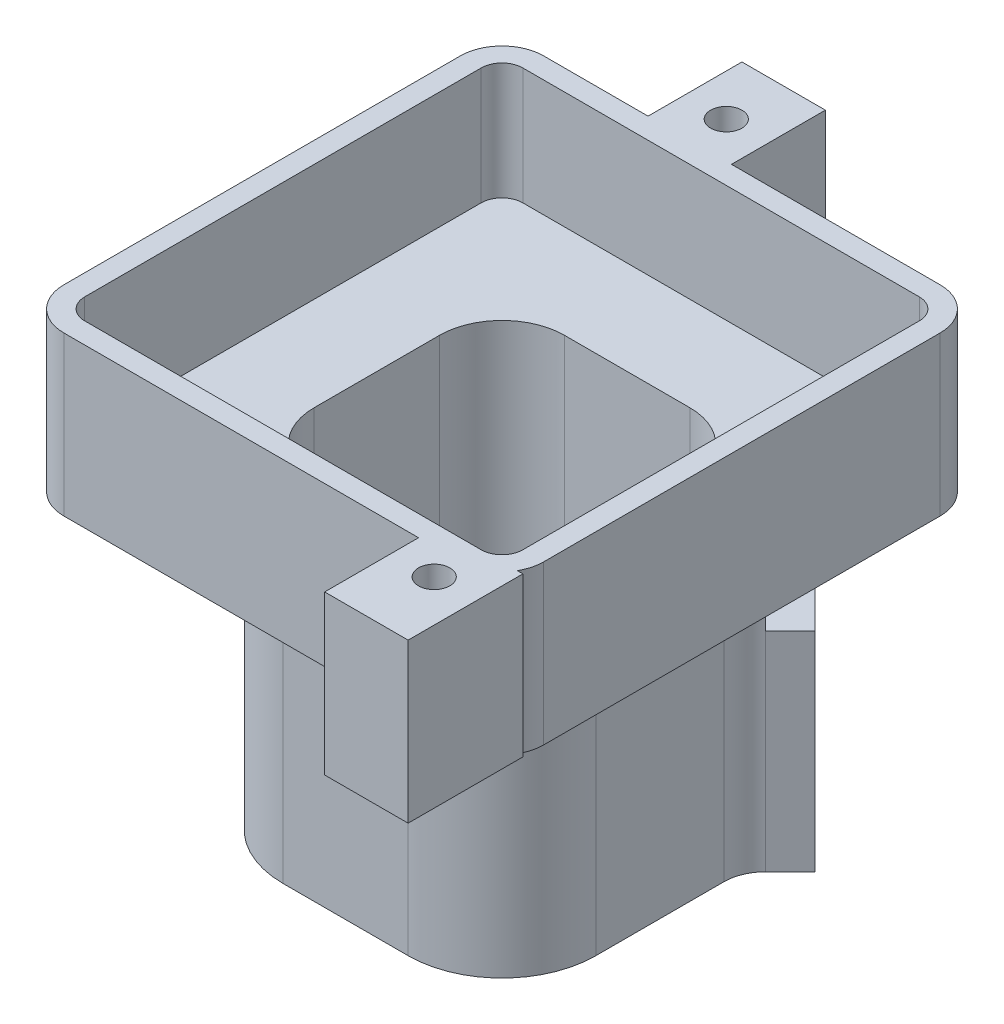
from build123d import *

# Parameters (mm, degrees)
SKETCH1_W                     = 7.5
SKETCH1_H                     = 7.5
BOSS_EXTRUDE1_DEPTH           = 7
SKETCH2_W                     = 11.5
SKETCH2_H                     = 11.5
BOSS_EXTRUDE2_DEPTH           = 3.8
SKETCH3_W                     = 6
SKETCH3_H                     = 6
CUT_EXTRUDE1_DEPTH            = 11.8
SKETCH6_W                     = 10.5
SKETCH6_H                     = 10.5
CUT_EXTRUDE3_DEPTH            = 2.8
FILLET1_R                     = 0.5
BOSS_EXTRUDE3_REACH           = 12.8
FILLET4_R                     = 1.5
FILLET2_R                     = 1
TAP_DRILL_FOR_0_80_TAP1_D     = 1.19126
TAP_DRILL_FOR_0_80_TAP1_DEPTH = 7.11
TAP_DRILL_FOR_0_80_TAP1_TIP   = 0.357890611
FILLET5_R                     = 2.25
SKETCH16_W                    = 2.5
SKETCH16_H                    = 2
CUT_EXTRUDE4_DEPTH            = 0.835786
FILLET6_R                     = 1
SKETCH17_W                    = 2
SKETCH17_H                    = 2.25
SKETCH17_H_2                  = 2.75
BOSS_EXTRUDE4_DEPTH           = 3.8
SKETCH18_R                    = 0.375
CUT_EXTRUDE5_DEPTH            = 11.8000001


with BuildPart() as part:
    # Sketch1 → Boss-Extrude1 (new body)
    with BuildSketch(Plane(origin=(0, 0, 0), x_dir=(1, 0, 0), z_dir=(0, 1, 0))):
        Rectangle(SKETCH1_W, SKETCH1_H)
    extrude(amount=BOSS_EXTRUDE1_DEPTH)

    # Sketch2 → Boss-Extrude2 (add)
    with BuildSketch(Plane(origin=(0, 7, 0), x_dir=(1, 0, 0), z_dir=(0, 1, 0))):
        Rectangle(SKETCH2_W, SKETCH2_H)
    extrude(amount=BOSS_EXTRUDE2_DEPTH)

    # Sketch3 → Cut-Extrude1 (cut, through all)
    with BuildSketch(Plane.XZ):
        Rectangle(SKETCH3_W, SKETCH3_H)
    extrude(amount=-CUT_EXTRUDE1_DEPTH, mode=Mode.SUBTRACT)

    # Sketch6 → Cut-Extrude3 (cut)
    with BuildSketch(Plane(origin=(0, 10.8, 0), x_dir=(1, 0, 0), z_dir=(0, 1, 0))):
        Rectangle(SKETCH6_W, SKETCH6_H)
    extrude(amount=-CUT_EXTRUDE3_DEPTH, mode=Mode.SUBTRACT)

    # Fillet1
    fillet1_edges = [part.edges().sort_by_distance(p)[0] for p in [
        (5.25, 9.4, 5.25),
        (5.25, 9.4, -5.25),
        (-5.25, 9.4, -5.25),
        (-5.25, 9.4, 5.25),
    ]]
    fillet(fillet1_edges, radius=FILLET1_R)

    # Sketch12 → Boss-Extrude3 (add, up to next)
    with BuildSketch(Plane.XZ, mode=Mode.PRIVATE) as boss_extrude3_sk1:
        Polygon((3.75, -3.75), (4.633883476, -2.866116524), (3.75, -1.982233047), align=None)
    boss_extrude3_tool1 = extrude(boss_extrude3_sk1.sketch, amount=-BOSS_EXTRUDE3_REACH, mode=Mode.PRIVATE) - part.part
    add(boss_extrude3_tool1.solids().sort_by_distance((4.044628, 0, -2.866117))[0])
    # Sketch12 → Boss-Extrude3 (add, up to next)
    with BuildSketch(Plane.XZ, mode=Mode.PRIVATE) as boss_extrude3_sk2:
        Polygon((2.866116524, -4.633883476), (3.75, -3.75), (1.982233047, -3.75), align=None)
    boss_extrude3_tool2 = extrude(boss_extrude3_sk2.sketch, amount=-BOSS_EXTRUDE3_REACH, mode=Mode.PRIVATE) - part.part
    add(boss_extrude3_tool2.solids().sort_by_distance((2.866117, 0, -4.044628))[0])

    # Fillet4
    fillet4_edges = [part.edges().sort_by_distance(p)[0] for p in [
        (-3, 4, 3),
        (3, 4, 3),
        (-3, 4, -3),
        (3, 4, -3),
    ]]
    fillet(fillet4_edges, radius=FILLET4_R)

    # Fillet2
    fillet2_edges = [part.edges().sort_by_distance(p)[0] for p in [
        (3.75, 3.5, -1.982233047),
        (1.982233047, 3.5, -3.75),
    ]]
    fillet(fillet2_edges, radius=FILLET2_R)

    # Tap Drill for #0-80 Tap1
    with Locations(Plane(origin=(3.75, 0, -3.75), x_dir=(-0.707106781, 0, -0.707106781), z_dir=(0.707106781, 0, -0.707106781))):
        with Locations((0, 1.25), (0, 3.75)):
            Hole(TAP_DRILL_FOR_0_80_TAP1_D / 2, depth=TAP_DRILL_FOR_0_80_TAP1_DEPTH)
            with Locations((0, 0, -(TAP_DRILL_FOR_0_80_TAP1_DEPTH + TAP_DRILL_FOR_0_80_TAP1_TIP / 2))):  # 118° drill point
                Cone(0, TAP_DRILL_FOR_0_80_TAP1_D / 2, TAP_DRILL_FOR_0_80_TAP1_TIP, mode=Mode.SUBTRACT)

    # Fillet5
    fillet5_edges = [part.edges().sort_by_distance(p)[0] for p in [
        (3.75, 3.5, 3.75),
        (-3.75, 3.5, 3.75),
        (-3.75, 3.5, -3.75),
    ]]
    fillet(fillet5_edges, radius=FILLET5_R)

    # Sketch16 → Cut-Extrude4 (cut)
    with BuildSketch(Plane(origin=(3.75, 0, -3.75), x_dir=(-0.707106781, 0, -0.707106781), z_dir=(0.707106781, 0, -0.707106781))):
        with Locations((0, 6)):
            Rectangle(SKETCH16_W, SKETCH16_H)
    extrude(amount=-CUT_EXTRUDE4_DEPTH, mode=Mode.SUBTRACT)

    # Fillet6
    fillet6_edges = [part.edges().sort_by_distance(p)[0] for p in [
        (-5.75, 8.9, -5.75),
        (-5.75, 8.9, 5.75),
        (5.75, 8.9, 5.75),
        (5.75, 8.9, -5.75),
    ]]
    fillet(fillet6_edges, radius=FILLET6_R)

    # Sketch17 → Boss-Extrude4 (add)
    with BuildSketch(Plane(origin=(0, 10.8, 0), x_dir=(1, 0, 0), z_dir=(0, 1, 0))):
        with Locations((-1.25, 6.875)):
            Rectangle(SKETCH17_W, SKETCH17_H)
        with Locations((4.75, -6.625)):
            Rectangle(SKETCH17_W, SKETCH17_H_2)
    extrude(amount=-BOSS_EXTRUDE4_DEPTH)

    # Sketch18 → Cut-Extrude5 (cut, through all)
    with BuildSketch(Plane(origin=(0, 10.8, 0), x_dir=(1, 0, 0), z_dir=(0, 1, 0))):
        with Locations((4.75, -6.375)):
            Circle(SKETCH18_R)
        with Locations((-1.25, 6.625)):
            Circle(SKETCH18_R)
    extrude(amount=-CUT_EXTRUDE5_DEPTH, mode=Mode.SUBTRACT)


solid = part.part
